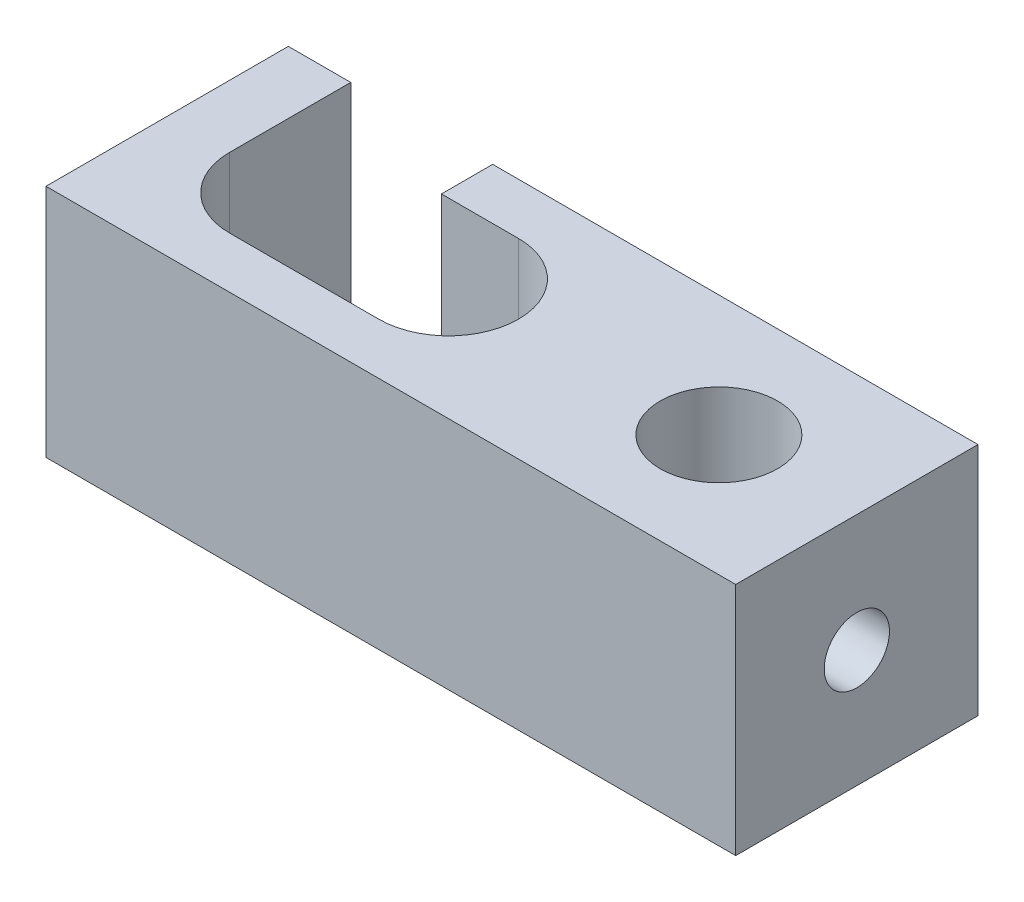
from build123d import *

# Parameters (mm, degrees)
SKETCH1_R                   = 1.575
BOSS_EXTRUDE1_DEPTH         = 3.15
BOSS_EXTRUDE1_DEPTH_BACK    = 3.15
M2X0_25_TAPPED_HOLE1_D      = 1.75
M2X0_25_TAPPED_HOLE1_DEPTH  = 1.675
M2X0_25_TAPPED_HOLE2_REACH  = 21.046
M2X0_25_TAPPED_HOLE2_BORE_R = 0.875


with BuildPart() as part:
    # Sketch1 → Boss-Extrude1 (new, two sides)
    with BuildSketch(Plane(origin=(0, 0, 0), x_dir=(1, 0, 0), z_dir=(0, 1, 0))) as boss_extrude1_sk:
        with BuildLine():
            Line((-7.575, 3.25), (-9.25, 3.25))
            Line((-9.25, 3.25), (-9.25, -3.25))
            Line((-9.25, -3.25), (9.25, -3.25))
            Line((9.25, -3.25), (9.25, 3.25))
            Line((9.25, 3.25), (-3.76833041, 3.25))
            Line((-3.76833041, 3.25), (-3.76833041, 1.875))
            Line((-3.76833041, 1.875), (-1.7, 1.875))
            ThreePointArc((-1.7, 1.875), (0.175, 0), (-1.7, -1.875))
            Line((-1.7, -1.875), (-5.7, -1.875))
            ThreePointArc((-5.7, -1.875), (-7.025825215, -1.325825215), (-7.575, 0))
            Line((-7.575, 0), (-7.575, 3.25))
        make_face()
        with Locations(Location((5.55, 0, 0), (0, 0, 270))):
            Circle(SKETCH1_R, mode=Mode.SUBTRACT)
    extrude(amount=BOSS_EXTRUDE1_DEPTH)
    extrude(boss_extrude1_sk.sketch, amount=-BOSS_EXTRUDE1_DEPTH_BACK)

    # M2x0.25 Tapped Hole1
    with Locations(Plane.ZY.offset(9.25)):
        with Locations((0, 0)):
            Hole(M2X0_25_TAPPED_HOLE1_D / 2, depth=M2X0_25_TAPPED_HOLE1_DEPTH)

    # M2x0.25 Tapped Hole2 bore → M2x0.25 Tapped Hole2 (cut, up to next)
    with BuildSketch(Plane(origin=(9.25, 0, 0), x_dir=(0, 0, -1), z_dir=(1, 0, 0)), mode=Mode.PRIVATE) as m2x0_25_tapped_hole2_sk1:
        Circle(M2X0_25_TAPPED_HOLE2_BORE_R)
    m2x0_25_tapped_hole2_tool1 = extrude(m2x0_25_tapped_hole2_sk1.sketch, amount=-M2X0_25_TAPPED_HOLE2_REACH, mode=Mode.PRIVATE) & part.part
    add(m2x0_25_tapped_hole2_tool1.solids().sort_by_distance((9.25, 0, 0))[0], mode=Mode.SUBTRACT)


solid = part.part
